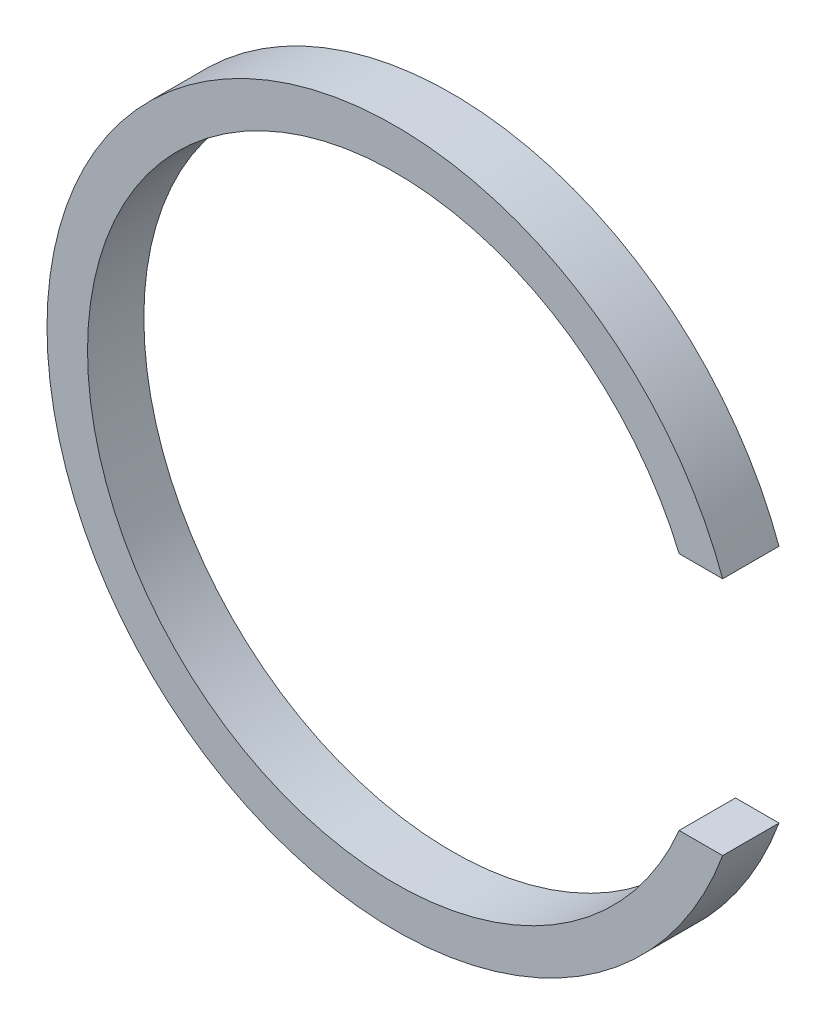
from build123d import *

# Parameters (mm, degrees)
BOSS_EXTRUDE1_DEPTH = 13.9


with BuildPart() as part:
    # Sketch1 → Boss-Extrude1 (new body)
    with BuildSketch(Plane.XY):
        with BuildLine():
            Line((70.009432938, 29.574977595), (80.754694602, 29.574977595))
            ThreePointArc((80.754694602, 29.574977595), (-86, 5.3419e-05), (80.754657861, -29.575077916))
            Line((80.754657861, -29.575077916), (70.009390558, -29.575077916))
            ThreePointArc((70.009390558, -29.575077916), (-76, 5.4453e-05), (70.009432938, 29.574977595))
        make_face()
    extrude(amount=BOSS_EXTRUDE1_DEPTH)


solid = part.part
